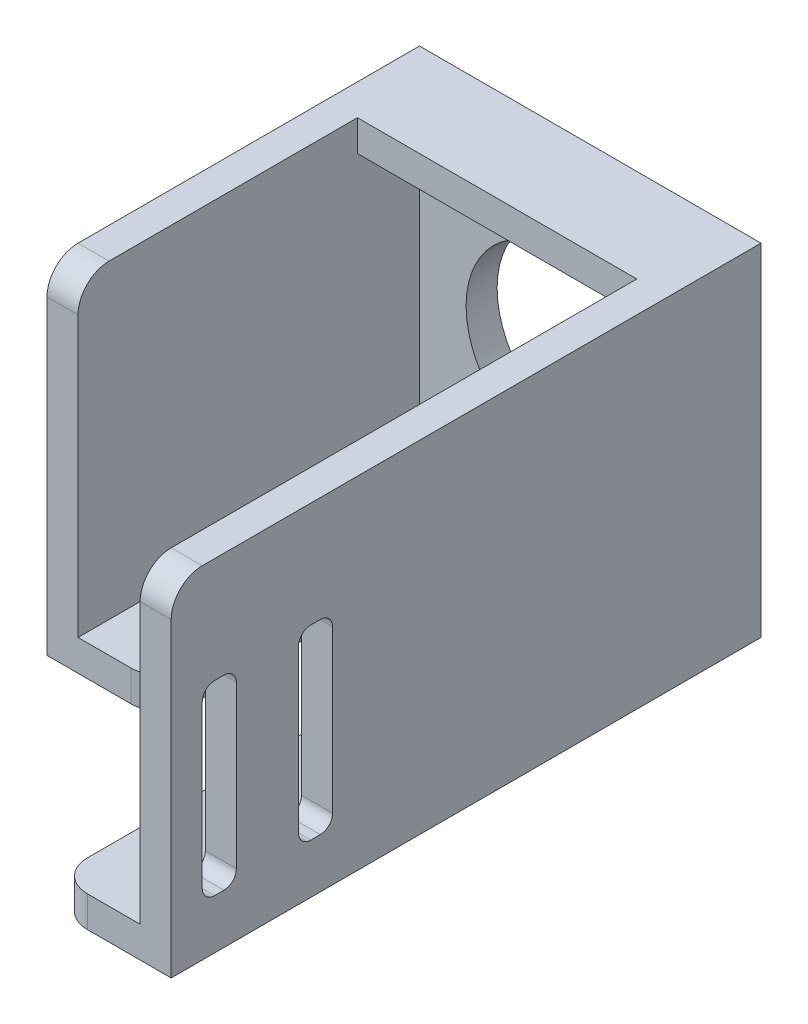
from build123d import *

# Parameters (mm, degrees)
CROQUIS1_W              = 55
CROQUIS1_H              = 55
SALIENTE_EXTRUIR1_DEPTH = 60
CROQUIS2_W              = 45
CROQUIS2_H              = 45
CORTAR_EXTRUIR1_DEPTH   = 55
CORTAR_EXTRUIR2_REACH   = 57
CROQUIS3_W              = 18
CROQUIS3_H              = 40
CORTAR_EXTRUIR3_REACH   = 57
CROQUIS4_W              = 45
CROQUIS4_H              = 45
CORTAR_EXTRUIR4_REACH   = 62
CROQUIS5_R              = 1.5
CROQUIS5_R_2            = 15
SALIENTE_EXTRUIR2_DEPTH = 35
REDONDEO3_R             = 5
CORTAR_EXTRUIR5_REACH   = 7
CROQUIS7_W              = 5.5
CROQUIS7_H              = 30
REDONDEO4_R             = 2


with BuildPart() as part:
    # Croquis1 → Saliente-Extruir1 (new body)
    with BuildSketch(Plane.XY):
        with Locations((27.5, -27.5)):
            Rectangle(CROQUIS1_W, CROQUIS1_H)
    extrude(amount=SALIENTE_EXTRUIR1_DEPTH)

    # Croquis2 → Cortar-Extruir1 (cut)
    with BuildSketch(Plane.XY.offset(60)):
        with Locations((27.5, -27.5)):
            Rectangle(CROQUIS2_W, CROQUIS2_H)
    extrude(amount=-CORTAR_EXTRUIR1_DEPTH, mode=Mode.SUBTRACT)

    # Croquis3 → Cortar-Extruir2 (cut, up to next)
    with BuildSketch(Plane.XZ.offset(55), mode=Mode.PRIVATE) as cortar_extruir2_sk1:
        with Locations((27.5, 40)):
            Rectangle(CROQUIS3_W, CROQUIS3_H)
    cortar_extruir2_tool1 = extrude(cortar_extruir2_sk1.sketch, amount=-CORTAR_EXTRUIR2_REACH, mode=Mode.PRIVATE) & part.part
    add(cortar_extruir2_tool1.solids().sort_by_distance((27.5, -55, 40))[0], mode=Mode.SUBTRACT)

    # Croquis4 → Cortar-Extruir3 (cut, up to next)
    with BuildSketch(Plane(origin=(0, 0, 0), x_dir=(1, 0, 0), z_dir=(0, 1, 0)), mode=Mode.PRIVATE) as cortar_extruir3_sk1:
        with Locations((27.5, -37.5)):
            Rectangle(CROQUIS4_W, CROQUIS4_H)
    cortar_extruir3_tool1 = extrude(cortar_extruir3_sk1.sketch, amount=-CORTAR_EXTRUIR3_REACH, mode=Mode.PRIVATE) & part.part
    add(cortar_extruir3_tool1.solids().sort_by_distance((27.5, 0, 37.5))[0], mode=Mode.SUBTRACT)

    # Croquis5 → Cortar-Extruir4 (cut, up to next)
    with BuildSketch(Plane(origin=(0, 0, 0), x_dir=(-1, 0, 0), z_dir=(0, 0, -1)), mode=Mode.PRIVATE) as cortar_extruir4_sk1:
        with Locations((-45, -10)):
            Circle(CROQUIS5_R)
    cortar_extruir4_tool1 = extrude(cortar_extruir4_sk1.sketch, amount=-CORTAR_EXTRUIR4_REACH, mode=Mode.PRIVATE) & part.part
    add(cortar_extruir4_tool1.solids().sort_by_distance((45, -10, 0))[0], mode=Mode.SUBTRACT)
    # Croquis5 → Cortar-Extruir4 (cut, up to next)
    with BuildSketch(Plane(origin=(0, 0, 0), x_dir=(-1, 0, 0), z_dir=(0, 0, -1)), mode=Mode.PRIVATE) as cortar_extruir4_sk2:
        with Locations((-10, -10)):
            Circle(CROQUIS5_R)
    cortar_extruir4_tool2 = extrude(cortar_extruir4_sk2.sketch, amount=-CORTAR_EXTRUIR4_REACH, mode=Mode.PRIVATE) & part.part
    add(cortar_extruir4_tool2.solids().sort_by_distance((10, -10, 0))[0], mode=Mode.SUBTRACT)
    # Croquis5 → Cortar-Extruir4 (cut, up to next)
    with BuildSketch(Plane(origin=(0, 0, 0), x_dir=(-1, 0, 0), z_dir=(0, 0, -1)), mode=Mode.PRIVATE) as cortar_extruir4_sk3:
        with Locations((-45, -45)):
            Circle(CROQUIS5_R)
    cortar_extruir4_tool3 = extrude(cortar_extruir4_sk3.sketch, amount=-CORTAR_EXTRUIR4_REACH, mode=Mode.PRIVATE) & part.part
    add(cortar_extruir4_tool3.solids().sort_by_distance((45, -45, 0))[0], mode=Mode.SUBTRACT)
    # Croquis5 → Cortar-Extruir4 (cut, up to next)
    with BuildSketch(Plane(origin=(0, 0, 0), x_dir=(-1, 0, 0), z_dir=(0, 0, -1)), mode=Mode.PRIVATE) as cortar_extruir4_sk4:
        with Locations((-10, -45)):
            Circle(CROQUIS5_R)
    cortar_extruir4_tool4 = extrude(cortar_extruir4_sk4.sketch, amount=-CORTAR_EXTRUIR4_REACH, mode=Mode.PRIVATE) & part.part
    add(cortar_extruir4_tool4.solids().sort_by_distance((10, -45, 0))[0], mode=Mode.SUBTRACT)
    # Croquis5 → Cortar-Extruir4 (cut, up to next)
    with BuildSketch(Plane(origin=(0, 0, 0), x_dir=(-1, 0, 0), z_dir=(0, 0, -1)), mode=Mode.PRIVATE) as cortar_extruir4_sk5:
        with Locations((-27.5, -27.5)):
            Circle(CROQUIS5_R_2)
    cortar_extruir4_tool5 = extrude(cortar_extruir4_sk5.sketch, amount=-CORTAR_EXTRUIR4_REACH, mode=Mode.PRIVATE) & part.part
    add(cortar_extruir4_tool5.solids().sort_by_distance((27.5, -27.5, 0))[0], mode=Mode.SUBTRACT)

    # Croquis6 → Saliente-Extruir2 (add)
    with BuildSketch(Plane.XY.offset(60)):
        Polygon((50, 0), (55, 0), (55, -55), (36.5, -55), (36.5, -50), (50, -50), align=None)
    extrude(amount=SALIENTE_EXTRUIR2_DEPTH)

    # Redondeo3
    redondeo3_edges = [part.edges().sort_by_distance(p)[0] for p in [
        (36.5, -52.5, 20),
        (18.5, -52.5, 60),
        (18.5, -52.5, 20),
        (2.5, 0, 60),
        (36.5, -52.5, 95),
        (52.5, 0, 95),
    ]]
    fillet(redondeo3_edges, radius=REDONDEO3_R)

    # Croquis7 → Cortar-Extruir5 (cut, up to next)
    with BuildSketch(Plane.ZY.offset(-50), mode=Mode.PRIVATE) as cortar_extruir5_sk1:
        with Locations((87.25, -32)):
            Rectangle(CROQUIS7_W, CROQUIS7_H)
    cortar_extruir5_tool1 = extrude(cortar_extruir5_sk1.sketch, amount=-CORTAR_EXTRUIR5_REACH, mode=Mode.PRIVATE) & part.part
    add(cortar_extruir5_tool1.solids().sort_by_distance((50, -32, 87.25))[0], mode=Mode.SUBTRACT)
    # Croquis7 → Cortar-Extruir5 (cut, up to next)
    with BuildSketch(Plane.ZY.offset(-50), mode=Mode.PRIVATE) as cortar_extruir5_sk2:
        with Locations((71.75, -32)):
            Rectangle(CROQUIS7_W, CROQUIS7_H)
    cortar_extruir5_tool2 = extrude(cortar_extruir5_sk2.sketch, amount=-CORTAR_EXTRUIR5_REACH, mode=Mode.PRIVATE) & part.part
    add(cortar_extruir5_tool2.solids().sort_by_distance((50, -32, 71.75))[0], mode=Mode.SUBTRACT)

    # Redondeo4
    redondeo4_edges = [part.edges().sort_by_distance(p)[0] for p in [
        (52.5, -47, 84.5),
        (52.5, -17, 84.5),
        (52.5, -17, 90),
        (52.5, -47, 90),
        (52.5, -47, 69),
        (52.5, -17, 69),
        (52.5, -17, 74.5),
        (52.5, -47, 74.5),
    ]]
    fillet(redondeo4_edges, radius=REDONDEO4_R)


solid = part.part
